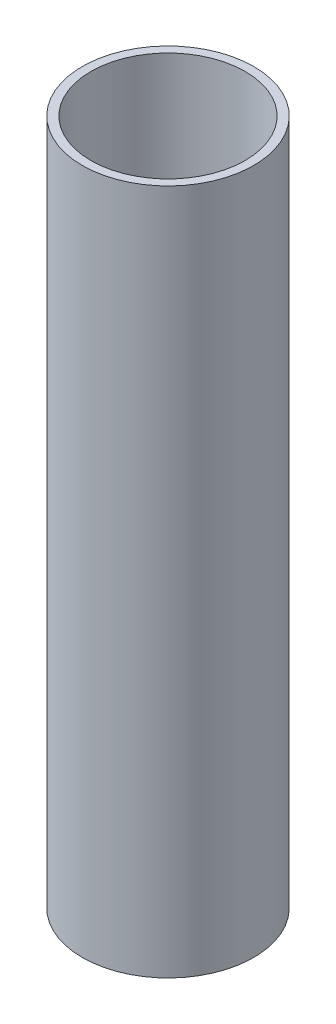
from build123d import *

# Parameters (mm, degrees)
SKETCH1_R           = 50
SKETCH1_R_2         = 45
BOSS_EXTRUDE1_DEPTH = 400


with BuildPart() as part:
    # Sketch1 → Boss-Extrude1 (new body)
    with BuildSketch(Plane(origin=(0, 0, 0), x_dir=(1, 0, 0), z_dir=(0, 1, 0))):
        Circle(SKETCH1_R)
        Circle(SKETCH1_R_2, mode=Mode.SUBTRACT)
    extrude(amount=BOSS_EXTRUDE1_DEPTH)


solid = part.part
